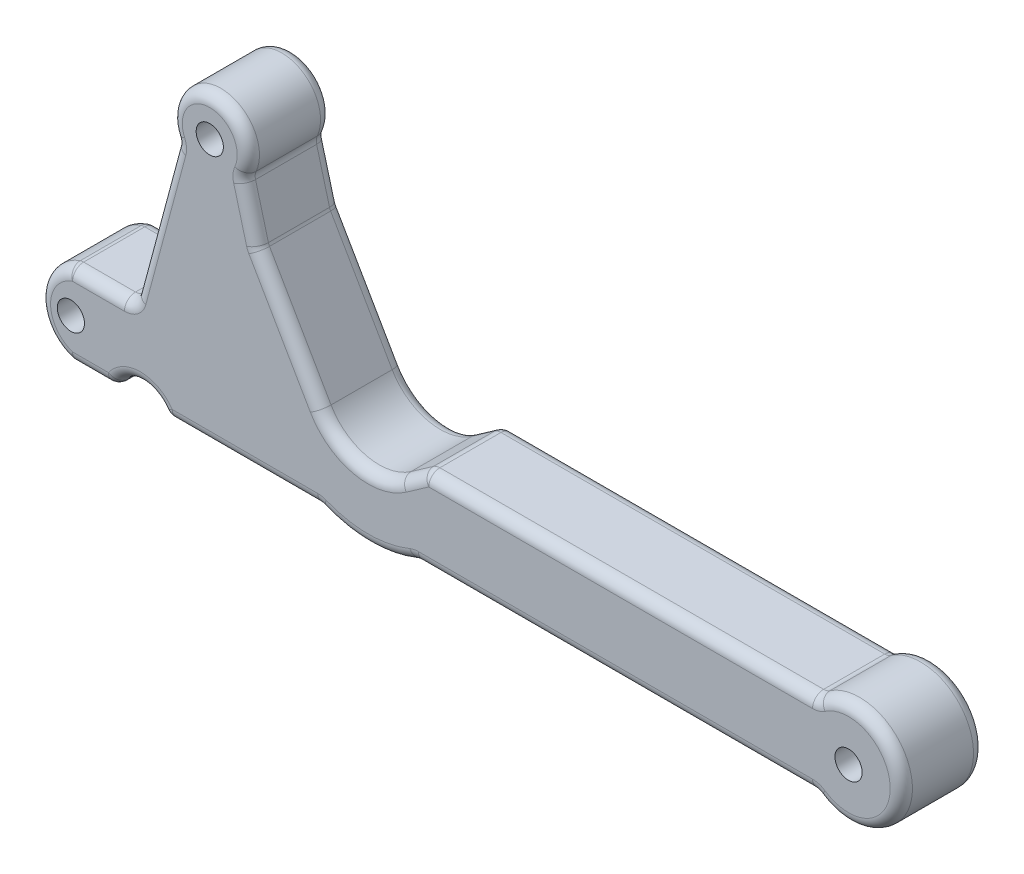
from build123d import *

# Parameters (mm, degrees)
SKETCH2_R               = 3.1115
BOSS_EXTRUDE1_DEPTH     = 9.525
SKETCH2_4_R             = 3.1115
BOSS_EXTRUDE2_DEPTH     = 9.525
CUT_EXTRUDE1_DEPTH      = 118.643428853
CUT_EXTRUDE1_DEPTH_BACK = 118.643428853
FILLET3_R               = 2.54


with BuildPart() as part:
    # Sketch2 → Boss-Extrude1 (new, symmetric)
    with BuildSketch(Plane.XY):
        with BuildLine():
            ThreePointArc((-88.9, 9.525), (-96.085115769, 0), (-88.9, -9.525))
            Line((-88.9, -9.525), (-78.844871133, -9.525))
            ThreePointArc((-78.844871133, -9.525), (-73.025, -5.715), (-67.205128867, -9.525))
            Line((-67.205128867, -9.525), (81.494691094, -9.525))
            ThreePointArc((81.494691094, -9.525), (100.965, 0), (81.494691094, 9.525))
            Line((81.494691094, 9.525), (-88.9, 9.525))
        make_face()
        with Locations((-88.9, 0)):
            Circle(SKETCH2_R, mode=Mode.SUBTRACT)
        with Locations((88.9, 0)):
            Circle(SKETCH2_R, mode=Mode.SUBTRACT)
    extrude(amount=BOSS_EXTRUDE1_DEPTH, both=True)

    # Sketch2_4 → Boss-Extrude2 (add, symmetric)
    # profile 1 of 3: a face of its own
    with BuildSketch(Plane.XY):
        with BuildLine():
            Line((-64.82586458, 46.442454223), (-74.717866626, 9.525))
            Line((-74.717866626, 9.525), (-31.953522628, 9.525))
            Line((-31.953522628, 9.525), (-46.188704076, 34.181057523))
            Line((-46.188704076, 34.181057523), (-49.47413542, 46.442454223))
            ThreePointArc((-49.47413542, 46.442454223), (-57.15, 59.6265), (-64.82586458, 46.442454223))
        make_face()
        with Locations((-57.15, 50.8)):
            Circle(SKETCH2_4_R, mode=Mode.SUBTRACT)
    # profile 2 of 3: a face of its own
    with BuildSketch(Plane.XY):
        with BuildLine():
            Line((-9.956477372, -9.525), (-31.953522628, -9.525))
            ThreePointArc((-31.953522628, -9.525), (-20.955, -11.804008291), (-9.956477372, -9.525))
        make_face()
    # profile 3 of 3: a face of its own
    with BuildSketch(Plane.XY):
        with BuildLine():
            ThreePointArc((79.375, -9.525), (74.295, -6.985), (69.215, -9.525))
            Line((69.215, -9.525), (79.375, -9.525))
        make_face()
    extrude(amount=BOSS_EXTRUDE2_DEPTH, both=True)

    # Sketch2_5 → Cut-Extrude1 (cut, two sides: drawn at the far end of the back side and taken through both)
    with BuildSketch(Plane.XY.offset(-CUT_EXTRUDE1_DEPTH_BACK)):
        with BuildLine():
            ThreePointArc((-67.205128867, -9.525), (-73.025, -5.715), (-78.844871133, -9.525))
            Line((-78.844871133, -9.525), (-67.205128867, -9.525))
        make_face()
        with BuildLine():
            ThreePointArc((-31.953522628, 9.525), (-23.703783097, 3.47604071), (-13.670579258, 5.471769038))
            Line((-13.670579258, 5.471769038), (-7.881965538, 9.525))
            Line((-7.881965538, 9.525), (-31.953522628, 9.525))
        make_face()
    extrude(amount=CUT_EXTRUDE1_DEPTH + CUT_EXTRUDE1_DEPTH_BACK, mode=Mode.SUBTRACT)

    # Fillet3
    fillet3_edges = [part.edges().sort_by_distance(p)[0] for p in [
        (-57.15, 59.6265, -9.525),
        (-64.82586458, 46.442454223, 0),
        (-69.771865603, 27.983727112, -9.525),
        (-57.15, 59.6265, 9.525),
        (-49.47413542, 46.442454223, 0),
        (-47.831419748, 40.311755873, -9.525),
        (-74.717866626, 9.525, 0),
        (-69.771865603, 27.983727112, 9.525),
        (-81.808933313, 9.525, -9.525),
        (-47.831419748, 40.311755873, 9.525),
        (-46.188704076, 34.181057523, 0),
        (-39.071113352, 21.853028761, -9.525),
        (-81.808933313, 9.525, 9.525),
        (-88.9, 9.525, 0),
        (-96.085115769, 0, -9.525),
        (-39.071113352, 21.853028761, 9.525),
        (-23.703783097, 3.47604071, -9.525),
        (-96.085115769, 0, 9.525),
        (-88.9, -9.525, 0),
        (-83.872435566, -9.525, -9.525),
        (-23.703783097, 3.47604071, 9.525),
        (-10.776272398, 7.498384519, -9.525),
        (-78.844871133, -9.525, 0),
        (-83.872435566, -9.525, 9.525),
        (-73.025, -5.715, -9.525),
        (-7.881965538, 9.525, 0),
        (-10.776272398, 7.498384519, 9.525),
        (36.806362778, 9.525, -9.525),
        (-67.205128867, -9.525, 0),
        (-73.025, -5.715, 9.525),
        (-49.579325748, -9.525, -9.525),
        (81.494691094, 9.525, 0),
        (36.806362778, 9.525, 9.525),
        (100.965, 0, -9.525),
        (-20.955, -11.804008291, -9.525),
        (35.769106861, -9.525, -9.525),
        (-49.579325748, -9.525, 9.525),
        (-31.953522628, -9.525, 0),
        (100.965, 0, 9.525),
        (81.494691094, -9.525, 0),
        (-9.956477372, -9.525, 0),
        (-20.955, -11.804008291, 9.525),
        (35.769106861, -9.525, 9.525),
    ]]
    fillet(fillet3_edges, radius=FILLET3_R)


solid = part.part
